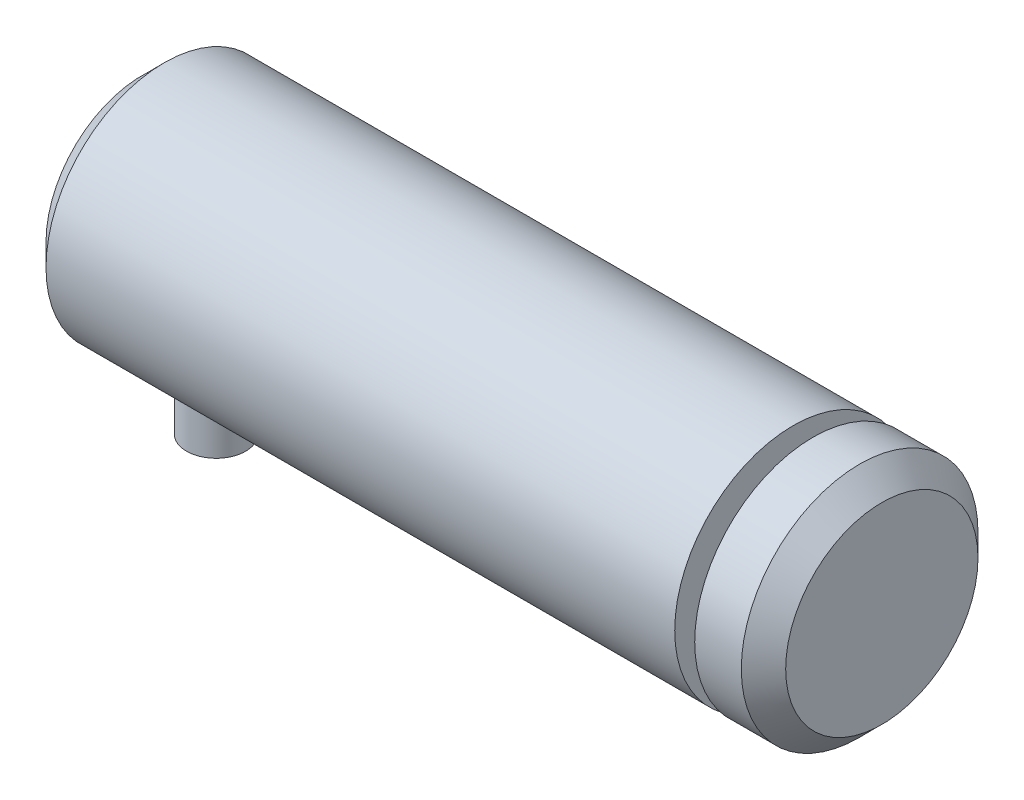
from build123d import *

# Parameters (mm, degrees)
SKETCH1_W           = 44
SKETCH1_H           = 8
SKETCH3_R           = 2
BOSS_EXTRUDE1_DEPTH = 12
SKETCH4_W           = 6
SKETCH4_H           = 8
SKETCH5_W           = 1.35
SKETCH5_H           = 2


with BuildPart() as part:
    # Sketch1 → Revolve1 (revolve)
    with BuildSketch(Plane.XY):
        with Locations((-3, 4)):
            Rectangle(SKETCH1_W, SKETCH1_H)
    revolve(axis=Axis((19, 0, 0), (-1, 0, 0)))

    # Sketch2 → Cut-Revolve1 (revolve, cut)
    with BuildSketch(Plane.XY):
        Polygon((-25, 6.5), (-23.5, 8), (-25, 8), align=None)
    revolve(axis=Axis((39, 0, 0), (-1, 0, 0)), mode=Mode.SUBTRACT)

    # Sketch3 → Boss-Extrude1 (add)
    with BuildSketch(Plane(origin=(0, 0, 0), x_dir=(1, 0, 0), z_dir=(0, 1, 0))):
        with Locations((-20, 0)):
            Circle(SKETCH3_R)
    extrude(amount=-BOSS_EXTRUDE1_DEPTH)

    # Sketch4 → Revolve2 (revolve)
    with BuildSketch(Plane.XY):
        with Locations((22, 4)):
            Rectangle(SKETCH4_W, SKETCH4_H)
    revolve(axis=Axis((25, 0, 0), (-1, 0, 0)))

    # Sketch5 → Cut-Revolve2 (revolve, cut)
    with BuildSketch(Plane.XY):
        with Locations((19.675, 7)):
            Rectangle(SKETCH5_W, SKETCH5_H)
    revolve(axis=Axis((39, 0, 0), (-1, 0, 0)), mode=Mode.SUBTRACT)

    # Sketch6 → Cut-Revolve3 (revolve, cut)
    with BuildSketch(Plane.XY):
        Polygon((23.5, 8), (25, 6.5), (25, 8), align=None)
    revolve(axis=Axis((39, 0, 0), (-1, 0, 0)), mode=Mode.SUBTRACT)


solid = part.part
